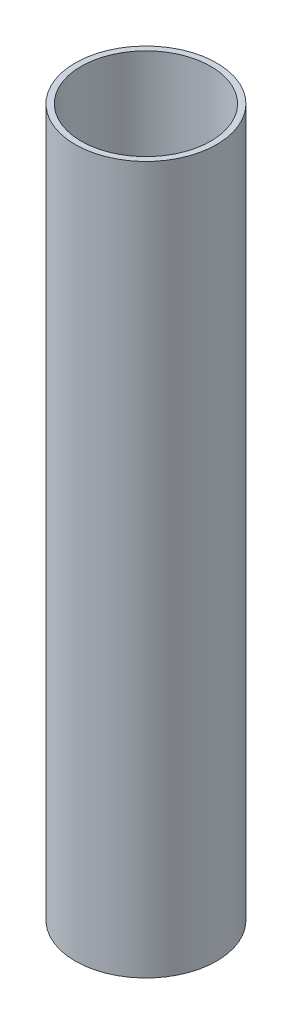
from build123d import *

# Parameters (mm, degrees)
SKETCH1_R           = 76.2
SKETCH1_R_2         = 69.85
BOSS_EXTRUDE1_DEPTH = 762


with BuildPart() as part:
    # Sketch1 → Boss-Extrude1 (new body)
    with BuildSketch(Plane(origin=(0, 0, 0), x_dir=(1, 0, 0), z_dir=(0, 1, 0))):
        with Locations(Location((0, 0, 0), (0, 0, 270))):  # turned: the seam where the file's is
            Circle(SKETCH1_R)
        with Locations(Location((0, 0, 0), (0, 0, 270))):  # turned: the seam where the file's is
            Circle(SKETCH1_R_2, mode=Mode.SUBTRACT)
    extrude(amount=BOSS_EXTRUDE1_DEPTH)


solid = part.part
